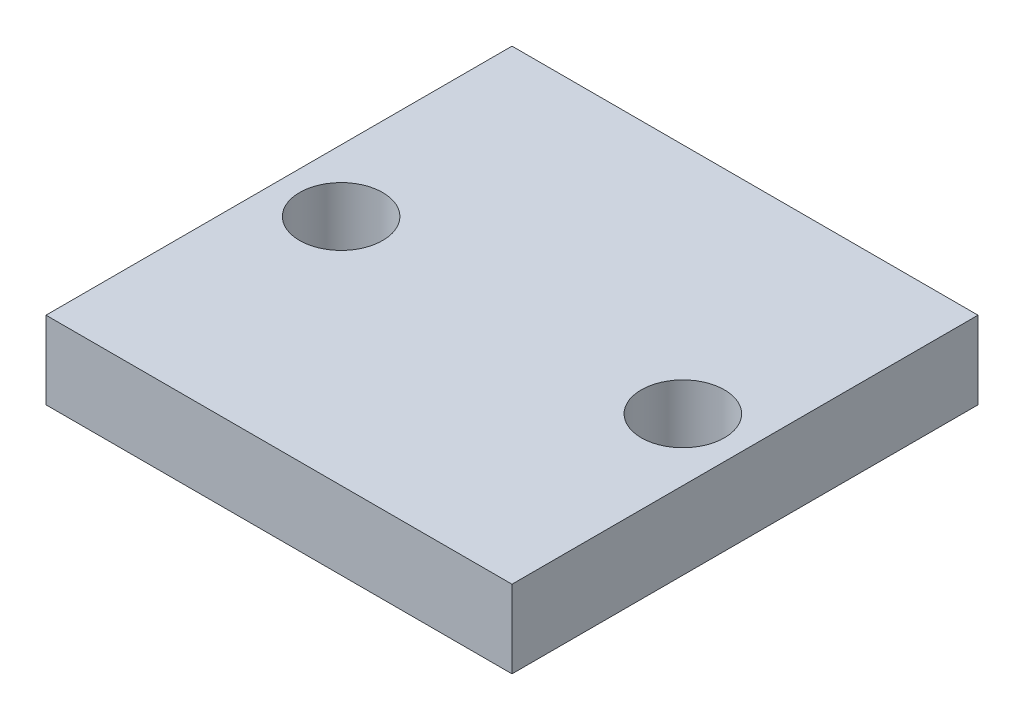
from build123d import *

# Parameters (mm, degrees)
SKETCH1_W                = 19.05
SKETCH1_H                = 19.05
BOSS_EXTRUDE1_DEPTH      = 3.175
M3_CLEARANCE_HOLE1_D     = 3.4
M3_CLEARANCE_HOLE1_DEPTH = 7.62
M3_CLEARANCE_HOLE1_TIP   = 1.021463052


with BuildPart() as part:
    # Sketch1 → Boss-Extrude1 (new body)
    with BuildSketch(Plane(origin=(0, 0, 0), x_dir=(1, 0, 0), z_dir=(0, 1, 0))):
        Rectangle(SKETCH1_W, SKETCH1_H)
    extrude(amount=BOSS_EXTRUDE1_DEPTH)

    # M3 Clearance Hole1
    with Locations(Plane(origin=(0, 3.175, 0), x_dir=(1, 0, 0), z_dir=(0, 1, 0))):
        with Locations((6.985, 0), (-6.985, 0)):
            Hole(M3_CLEARANCE_HOLE1_D / 2, depth=M3_CLEARANCE_HOLE1_DEPTH)
            with Locations((0, 0, -(M3_CLEARANCE_HOLE1_DEPTH + M3_CLEARANCE_HOLE1_TIP / 2))):  # 118° drill point
                Cone(0, M3_CLEARANCE_HOLE1_D / 2, M3_CLEARANCE_HOLE1_TIP, mode=Mode.SUBTRACT)


solid = part.part
